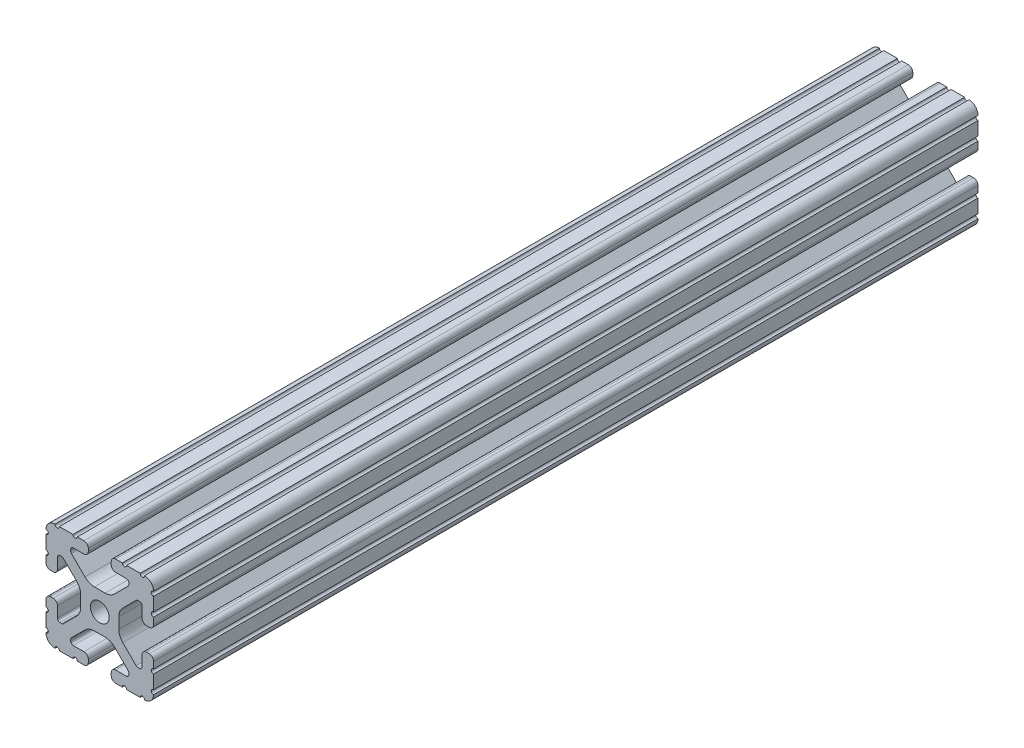
from build123d import *

# Parameters (mm, degrees)
SKETCH3_R                = 3.3274
BOSS_EXTRUDE1_DEPTH      = 457.2
BOSS_EXTRUDE1_DEPTH_BACK = 457.2
CUT_EXTRUDE1_DEPTH       = 22.86


with BuildPart() as part:
    # Sketch3 → Boss-Extrude1 (new body, two sides)
    with BuildSketch(Plane.XY) as boss_extrude1_sk:
        with BuildLine():
            Line((-4.064, 16.539617549), (-4.064, 17.496382451))
            ThreePointArc((-4.064, 17.496382451), (-4.519044045, 18.594955955), (-5.617617549, 19.05))
            Line((-5.617617549, 19.05), (-7.974178704, 19.05))
            ThreePointArc((-7.974178704, 19.05), (-8.736178704, 18.288), (-9.498178704, 19.05))
            Line((-9.498178704, 19.05), (-14.327719207, 19.05))
            ThreePointArc((-14.327719207, 19.05), (-15.087603123, 18.231251131), (-15.847487039, 19.05))
            ThreePointArc((-15.847487039, 19.05), (-18.120176289, 18.120192083), (-19.05, 15.847509295))
            ThreePointArc((-19.05, 15.847509295), (-18.231250992, 15.08762539), (-19.05, 14.327741484))
            Line((-19.05, 14.327741484), (-19.05, 9.496091471))
            ThreePointArc((-19.05, 9.496091471), (-18.231250992, 8.736207565), (-19.05, 7.97632366))
            Line((-19.05, 7.97632366), (-19.05, 5.617617549))
            ThreePointArc((-19.05, 5.617617549), (-18.594955955, 4.519044045), (-17.496382451, 4.064))
            Line((-17.496382451, 4.064), (-16.539617549, 4.064))
            ThreePointArc((-16.539617549, 4.064), (-15.441044045, 4.519044045), (-14.986, 5.617617549))
            Line((-14.986, 5.617617549), (-14.986, 9.385342516))
            ThreePointArc((-14.986, 9.385342516), (-14.721898185, 10.022940701), (-14.0843, 10.287042516))
            Line((-14.0843, 10.287042516), (-13.516042086, 10.287042516))
            ThreePointArc((-13.516042086, 10.287042516), (-13.170975923, 10.218404478), (-12.878443117, 10.022939917))
            Line((-12.878443117, 10.022939917), (-8.14758008, 5.292065243))
            ThreePointArc((-8.14758008, 5.292065243), (-7.117955879, 3.751120653), (-6.7564, 1.933453584))
            Line((-6.7564, 1.933453584), (-6.7564, -1.933453584))
            ThreePointArc((-6.7564, -1.933453584), (-7.117955879, -3.751120653), (-8.14758008, -5.292065243))
            Line((-8.14758008, -5.292065243), (-12.878443117, -10.022939917))
            ThreePointArc((-12.878443117, -10.022939917), (-13.170975923, -10.218404478), (-13.516042086, -10.287042516))
            Line((-13.516042086, -10.287042516), (-14.0843, -10.287042516))
            ThreePointArc((-14.0843, -10.287042516), (-14.721898185, -10.022940701), (-14.986, -9.385342516))
            Line((-14.986, -9.385342516), (-14.986, -5.617617549))
            ThreePointArc((-14.986, -5.617617549), (-15.441044045, -4.519044045), (-16.539617549, -4.064))
            Line((-16.539617549, -4.064), (-17.496382451, -4.064))
            ThreePointArc((-17.496382451, -4.064), (-18.594955955, -4.519044045), (-19.05, -5.617617549))
            Line((-19.05, -5.617617549), (-19.05, -7.976318491))
            ThreePointArc((-19.05, -7.976318491), (-18.231250992, -8.736202396), (-19.05, -9.496086302))
            Line((-19.05, -9.496086302), (-19.05, -14.32774291))
            ThreePointArc((-19.05, -14.32774291), (-18.231250992, -15.087626816), (-19.05, -15.847510721))
            ThreePointArc((-19.05, -15.847510721), (-18.120175716, -18.120192644), (-15.847486868, -19.05))
            ThreePointArc((-15.847486868, -19.05), (-15.087602952, -18.231251131), (-14.327719036, -19.05))
            Line((-14.327719036, -19.05), (-9.496062448, -19.05))
            ThreePointArc((-9.496062448, -19.05), (-8.736178532, -18.231251131), (-7.976294616, -19.05))
            Line((-7.976294616, -19.05), (-5.617617549, -19.05))
            ThreePointArc((-5.617617549, -19.05), (-4.519044045, -18.594955955), (-4.064, -17.496382451))
            Line((-4.064, -17.496382451), (-4.064, -16.539617549))
            ThreePointArc((-4.064, -16.539617549), (-4.519044045, -15.441044045), (-5.617617549, -14.986))
            Line((-5.617617549, -14.986), (-9.3853, -14.986))
            ThreePointArc((-9.3853, -14.986), (-10.022898185, -14.721898185), (-10.287, -14.0843))
            Line((-10.287, -14.0843), (-10.287, -13.552357131))
            ThreePointArc((-10.287, -13.552357131), (-10.218362387, -13.207291992), (-10.022898969, -12.91475973))
            Line((-10.022898969, -12.91475973), (-5.252158105, -8.144007132))
            ThreePointArc((-5.252158105, -8.144007132), (-3.715177372, -7.117027388), (-1.902183975, -6.7564))
            Line((-1.902183975, -6.7564), (1.902183975, -6.7564))
            ThreePointArc((1.902183975, -6.7564), (3.715177372, -7.117027388), (5.252158105, -8.144007132))
            Line((5.252158105, -8.144007132), (10.022898969, -12.91475973))
            ThreePointArc((10.022898969, -12.91475973), (10.218362387, -13.207291992), (10.287, -13.552357131))
            Line((10.287, -13.552357131), (10.287, -14.0843))
            ThreePointArc((10.287, -14.0843), (10.022898185, -14.721898185), (9.3853, -14.986))
            Line((9.3853, -14.986), (5.617617549, -14.986))
            ThreePointArc((5.617617549, -14.986), (4.519044045, -15.441044045), (4.064, -16.539617549))
            Line((4.064, -16.539617549), (4.064, -17.496382451))
            ThreePointArc((4.064, -17.496382451), (4.519044045, -18.594955955), (5.617617549, -19.05))
            Line((5.617617549, -19.05), (7.976294616, -19.05))
            ThreePointArc((7.976294616, -19.05), (8.736178532, -18.231251131), (9.496062448, -19.05))
            Line((9.496062448, -19.05), (14.327719036, -19.05))
            ThreePointArc((14.327719036, -19.05), (15.087602952, -18.231251131), (15.847486868, -19.05))
            ThreePointArc((15.847486868, -19.05), (18.120175716, -18.120192644), (19.05, -15.847510721))
            ThreePointArc((19.05, -15.847510721), (18.231250992, -15.087626816), (19.05, -14.32774291))
            Line((19.05, -14.32774291), (19.05, -9.496086302))
            ThreePointArc((19.05, -9.496086302), (18.231250992, -8.736202396), (19.05, -7.976318491))
            Line((19.05, -7.976318491), (19.05, -5.617617549))
            ThreePointArc((19.05, -5.617617549), (18.594955955, -4.519044045), (17.496382451, -4.064))
            Line((17.496382451, -4.064), (16.539617549, -4.064))
            ThreePointArc((16.539617549, -4.064), (15.441044045, -4.519044045), (14.986, -5.617617549))
            Line((14.986, -5.617617549), (14.986, -9.385342516))
            ThreePointArc((14.986, -9.385342516), (14.721898185, -10.022940701), (14.0843, -10.287042516))
            Line((14.0843, -10.287042516), (13.516042086, -10.287042516))
            ThreePointArc((13.516042086, -10.287042516), (13.170975923, -10.218404478), (12.878443117, -10.022939917))
            Line((12.878443117, -10.022939917), (8.14758008, -5.292065243))
            ThreePointArc((8.14758008, -5.292065243), (7.117955879, -3.751120653), (6.7564, -1.933453584))
            Line((6.7564, -1.933453584), (6.7564, 1.933453584))
            ThreePointArc((6.7564, 1.933453584), (7.117955879, 3.751120653), (8.14758008, 5.292065243))
            Line((8.14758008, 5.292065243), (12.878443117, 10.022939917))
            ThreePointArc((12.878443117, 10.022939917), (13.170975923, 10.218404478), (13.516042086, 10.287042516))
            Line((13.516042086, 10.287042516), (14.0843, 10.287042516))
            ThreePointArc((14.0843, 10.287042516), (14.721898185, 10.022940701), (14.986, 9.385342516))
            Line((14.986, 9.385342516), (14.986, 5.617617549))
            ThreePointArc((14.986, 5.617617549), (15.441044045, 4.519044045), (16.539617549, 4.064))
            Line((16.539617549, 4.064), (17.496382451, 4.064))
            ThreePointArc((17.496382451, 4.064), (18.594955955, 4.519044045), (19.05, 5.617617549))
            Line((19.05, 5.617617549), (19.05, 7.97632366))
            ThreePointArc((19.05, 7.97632366), (18.231250992, 8.736207565), (19.05, 9.496091471))
            Line((19.05, 9.496091471), (19.05, 14.327741484))
            ThreePointArc((19.05, 14.327741484), (18.231250992, 15.08762539), (19.05, 15.847509295))
            ThreePointArc((19.05, 15.847509295), (18.120176289, 18.120192083), (15.847487039, 19.05))
            ThreePointArc((15.847487039, 19.05), (15.087603123, 18.231251131), (14.327719207, 19.05))
            Line((14.327719207, 19.05), (9.498178704, 19.05))
            ThreePointArc((9.498178704, 19.05), (8.736178704, 18.288), (7.974178704, 19.05))
            Line((7.974178704, 19.05), (5.617617549, 19.05))
            ThreePointArc((5.617617549, 19.05), (4.519044045, 18.594955955), (4.064, 17.496382451))
            Line((4.064, 17.496382451), (4.064, 16.539617549))
            ThreePointArc((4.064, 16.539617549), (4.519044045, 15.441044045), (5.617617549, 14.986))
            Line((5.617617549, 14.986), (9.3853, 14.986))
            ThreePointArc((9.3853, 14.986), (10.022898185, 14.721898185), (10.287, 14.0843))
            Line((10.287, 14.0843), (10.287, 13.552357131))
            ThreePointArc((10.287, 13.552357131), (10.218362387, 13.207291992), (10.022898969, 12.91475973))
            Line((10.022898969, 12.91475973), (5.252158105, 8.144007132))
            ThreePointArc((5.252158105, 8.144007132), (3.715177372, 7.117027388), (1.902183975, 6.7564))
            Line((1.902183975, 6.7564), (-1.902183975, 6.7564))
            ThreePointArc((-1.902183975, 6.7564), (-3.715177372, 7.117027388), (-5.252158105, 8.144007132))
            Line((-5.252158105, 8.144007132), (-10.022898969, 12.91475973))
            ThreePointArc((-10.022898969, 12.91475973), (-10.218362387, 13.207291992), (-10.287, 13.552357131))
            Line((-10.287, 13.552357131), (-10.287, 14.0843))
            ThreePointArc((-10.287, 14.0843), (-10.022898185, 14.721898185), (-9.3853, 14.986))
            Line((-9.3853, 14.986), (-5.617617549, 14.986))
            ThreePointArc((-5.617617549, 14.986), (-4.519044045, 15.441044045), (-4.064, 16.539617549))
        make_face()
        Circle(SKETCH3_R, mode=Mode.SUBTRACT)
    extrude(amount=BOSS_EXTRUDE1_DEPTH)
    extrude(boss_extrude1_sk.sketch, amount=-BOSS_EXTRUDE1_DEPTH_BACK)

    # Sketch4 → Cut-Extrude1 (cut, symmetric)
    with BuildSketch(Plane(origin=(0, 0, 0), x_dir=(1, 0, 0), z_dir=(0, 1, 0))):
        Polygon((-11.912948955, 165.1), (-26.025980117, 165.1), (-26.025980117, -481.323002094), (32.635256624, -481.323002094), (32.635256624, 165.1), align=None)
    extrude(amount=CUT_EXTRUDE1_DEPTH, both=True, mode=Mode.SUBTRACT)


solid = part.part
